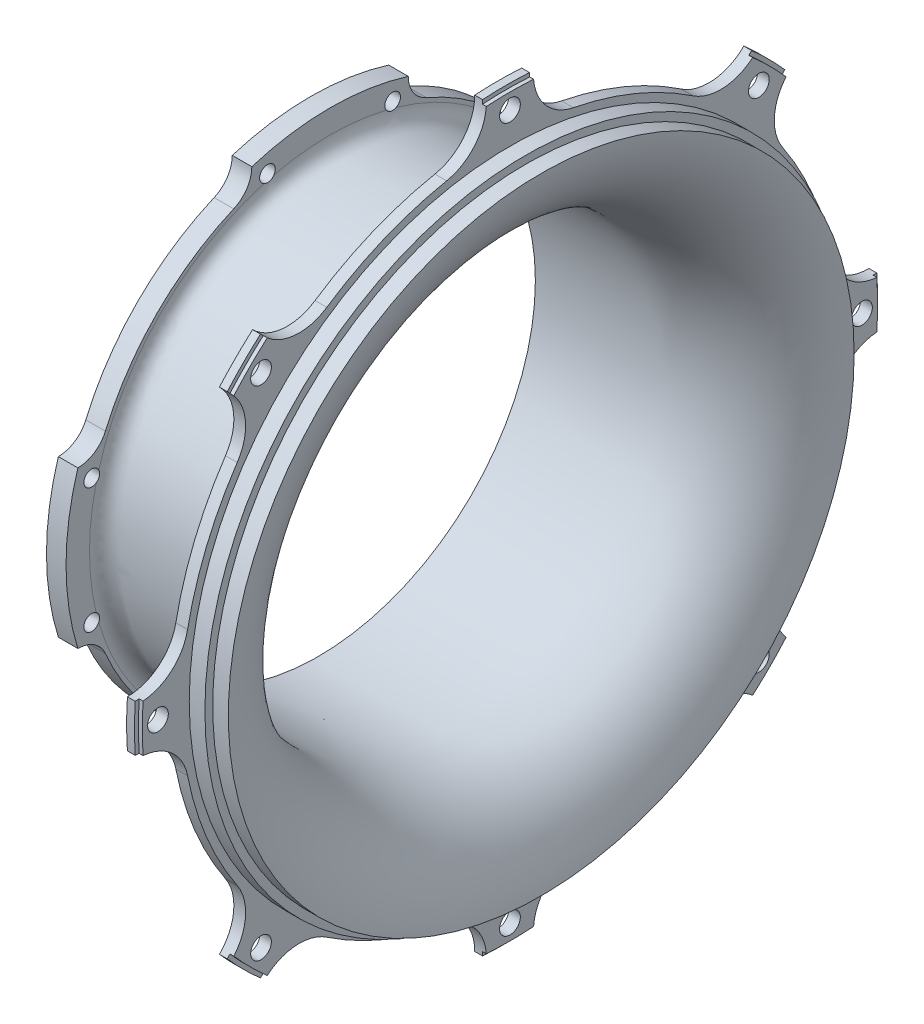
from build123d import *

# Parameters (mm, degrees)
BOSS_EXTRUDE1_DEPTH        = 3
M5_CLEARANCE_HOLE1_D       = 5.3
CIRPATTERN2_COUNT          = 8
SKETCH3_W                  = 1
SKETCH3_H                  = 1
BOSS_EXTRUDE2_DEPTH        = 5
M4_TAPPED_HOLE1_AT_2_COUNT = 2
M4_TAPPED_HOLE1_AT_2_PITCH = 32
CIRPATTERN3_COUNT          = 4


with BuildPart() as part:
    # Sketch1 → Revolve1 (revolve)
    with BuildSketch(Plane.XY, mode=Mode.PRIVATE) as revolve1_sk:
        with BuildLine():
            Line((26.884010118, 80), (22.884010118, 80))
            Line((22.884010118, 80), (22.884010118, 82))
            Line((22.884010118, 82), (18.884010118, 82))
            Line((18.884010118, 82), (18.884010118, 84))
            Line((18.884010118, 84), (15.884010118, 84))
            Line((15.884010118, 84), (15.884010118, 81))
            Line((15.884010118, 81), (22.904717658, 78.395093172))
            ThreePointArc((22.904717658, 78.395093172), (23.986444927, 77.436887697), (24.140215409, 76))
            add(Edge.make_bspline(
                [(24.140215409, 76), (21.925204116, 67.773715422), (16.096743453, 61.560255894), (8.028749254, 58.824291237), (7.172505876, 58.533927665), (5.428515706, 58.046099878), (2.71241102, 57.5), (0.904137007, 57.5), (0, 57.5), (-0.64211083, 57.5), (-1.92633249, 57.5), (-3.85266498, 57.5), (-5.136886641, 57.5), (-5.778997471, 57.5), (-11.037754083, 57.5), (-16.296510694, 57.5), (-21.555267306, 57.5), (-21.728680926, 57.5), (-22.075508165, 57.5), (-22.595749024, 57.5), (-22.942576263, 57.5), (-23.115989882, 57.5), (-23.289403502, 57.5), (-23.636230741, 57.5), (-24.157452607, 57.626231688), (-24.486510318, 57.738119351), (-24.646723612, 57.80448187), (-26.1887189, 58.443197231), (-27.115989882, 59.830956327), (-27.115989882, 61.5)],
                knots=[0, 0, 0, 0, 0.387277446, 0.387277446, 0.387277446, 0.431883511, 0.476489576, 0.521095641, 0.521095641, 0.521095641, 0.55277451, 0.584453379, 0.616132247, 0.616132247, 0.616132247, 0.875575715, 0.875575715, 0.875575715, 0.884131165, 0.892686615, 0.901242066, 0.901242066, 0.901242066, 0.909797516, 0.918352966, 0.926908417, 0.926908417, 0.926908417, 1, 1, 1, 1], degree=3, weights=[1, 0.921424889, 0.921424889, 1, 1, 1, 1, 1, 1, 1, 1, 1, 1, 1, 1, 1, 1, 1, 1, 1, 1, 1, 1, 1, 1, 1, 1, 0.887646408, 0.887646408, 1]))
            Line((-27.115989882, 61.5), (-27.115989882, 62.5))
            Line((-27.115989882, 62.5), (-32.115989882, 62.5))
            Line((-32.115989882, 62.5), (-32.115989882, 58.5))
            Line((-32.115989882, 58.5), (-30.115989882, 58.5))
            Line((-30.115989882, 58.5), (-30.115989882, 55.5))
            add(Edge.make_bspline(
                [(26.884010118, 80), (25.909531142, 69.520838946), (19.565470353, 61.123498988), (9.751475397, 57.322455887), (8.723618902, 56.924358389), (6.619149717, 56.254048066), (3.306771132, 55.5), (1.102257044, 55.5), (0, 55.5), (-0.836555275, 55.5), (-2.509665824, 55.5), (-5.019331647, 55.5), (-6.692442196, 55.5), (-7.528997471, 55.5), (-15.057994941, 55.5), (-22.586992412, 55.5), (-30.115989882, 55.5)],
                knots=[0, 0, 0, 0, 0.415170124, 0.415170124, 0.415170124, 0.463473748, 0.511777373, 0.560080997, 0.560080997, 0.560080997, 0.596740914, 0.633400831, 0.670060748, 0.670060748, 0.670060748, 1, 1, 1, 1], degree=3, weights=[1, 0.900187608, 0.900187608, 1, 1, 1, 1, 1, 1, 1, 1, 1, 1, 1, 1, 1, 1]))
        make_face()
    revolve(revolve1_sk.sketch.rotate(Axis((21.060706508, 0, 0), (-1, 0, 0)), 90), axis=Axis((21.060706508, 0, 0), (-1, 0, 0)))

    # Sketch2 → Boss-Extrude1 (add)
    with BuildSketch(Plane.ZY.offset(-15.884010118)):
        with BuildLine():
            ThreePointArc((6, 94.810336989), (0, 95), (-6, 94.810336989))
            ThreePointArc((-6, 94.810336989), (-8.874660383, 86.791417172), (-16.189212499, 82.425174544))
            ThreePointArc((-16.189212499, 82.425174544), (0, 84), (16.189212499, 82.425174544))
            ThreePointArc((16.189212499, 82.425174544), (8.874660383, 86.791417172), (6, 94.810336989))
        make_face()
    boss_extrude1 = extrude(amount=-BOSS_EXTRUDE1_DEPTH)

    # M5 Clearance Hole1 (through all)
    with Locations(Plane.ZY.offset(-15.884010118)):
        with Locations((0, 90)):
            m5_clearance_hole1 = Hole(M5_CLEARANCE_HOLE1_D / 2)

    # CirPattern2: Boss-Extrude1, M5 Clearance Hole1 ×8 about axis
    cirpattern2_axis = Axis((0, 0, 0), (1, 0, 0))
    add([boss_extrude1.rotate(cirpattern2_axis, i * 360 / CIRPATTERN2_COUNT) for i in range(1, CIRPATTERN2_COUNT)])
    add([m5_clearance_hole1.rotate(cirpattern2_axis, i * 360 / CIRPATTERN2_COUNT) for i in range(1, CIRPATTERN2_COUNT)], mode=Mode.SUBTRACT)

    # Sketch3 → Cut-Revolve1 (revolve, cut)
    with BuildSketch(Plane.XY):
        with Locations((18.384010118, 94.5)):
            Rectangle(SKETCH3_W, SKETCH3_H)
    revolve(axis=Axis((-27.669802315, 0, 0), (1, 0, 0)), mode=Mode.SUBTRACT)

    # Sketch8 → Boss-Extrude2 (add)
    with BuildSketch(Plane.ZY.offset(32.115989882)):
        with BuildLine():
            ThreePointArc((20, 64.468984791), (0, 67.5), (-20, 64.468984791))
            ThreePointArc((-20, 64.468984791), (-21.262497448, 60.260079388), (-24.63312369, 57.440919363))
            ThreePointArc((-24.63312369, 57.440919363), (0, 62.5), (24.63312369, 57.440919363))
            ThreePointArc((24.63312369, 57.440919363), (21.262497448, 60.260079388), (20, 64.468984791))
        make_face()
    boss_extrude2 = extrude(amount=-BOSS_EXTRUDE2_DEPTH)

    # Sketch9 → M4 Tapped Hole1 (revolve, cut)
    with BuildSketch(Plane(origin=(-32.115989882, 60.934390946, -16), x_dir=(0, 0, 1), z_dir=(0, 1, 0))):
        Polygon((0, 0), (0, 11.241420021), (1.65, 10.25), (1.65, 8), (2, 8), (2, 0), align=None)
    m4_tapped_hole1 = revolve(axis=Axis((-38.465989882, 60.934390946, -16), (1, 0, 0)), mode=Mode.SUBTRACT)

    # M4 Tapped Hole1 at 2: M4 Tapped Hole1 ×2
    with Locations(*[(0, 0, i * M4_TAPPED_HOLE1_AT_2_PITCH) for i in range(1, M4_TAPPED_HOLE1_AT_2_COUNT)]):
        add(m4_tapped_hole1, mode=Mode.SUBTRACT)

    # CirPattern3: Boss-Extrude2, M4 Tapped Hole1 ×4 about axis
    cirpattern3_axis = Axis((0, 0, 0), (1, 0, 0))
    add([boss_extrude2.rotate(cirpattern3_axis, i * 360 / CIRPATTERN3_COUNT) for i in range(1, CIRPATTERN3_COUNT)])
    add([m4_tapped_hole1.rotate(cirpattern3_axis, i * 360 / CIRPATTERN3_COUNT) for i in range(1, CIRPATTERN3_COUNT)], mode=Mode.SUBTRACT)

    # CirPattern3 copy 1 sketch → CirPattern3 copy 1 (revolve, cut)
    with BuildSketch(Plane(origin=(-32.115989882, -16, 60.934390946), x_dir=(0, -1, 0), z_dir=(0, 0, 1))):
        Polygon((0, 0), (0, 11.241420021), (1.65, 10.25), (1.65, 8), (2, 8), (2, 0), align=None)
    revolve(axis=Axis((-38.465989882, -16, 60.934390946), (1, 0, 0)), mode=Mode.SUBTRACT)

    # CirPattern3 copy 2 sketch → CirPattern3 copy 2 (revolve, cut)
    with BuildSketch(Plane(origin=(-32.115989882, -60.934390946, -16), x_dir=(0, 0, -1), z_dir=(0, -1, 0))):
        Polygon((0, 0), (0, 11.241420021), (1.65, 10.25), (1.65, 8), (2, 8), (2, 0), align=None)
    revolve(axis=Axis((-38.465989882, -60.934390946, -16), (1, 0, 0)), mode=Mode.SUBTRACT)

    # CirPattern3 copy 3 sketch → CirPattern3 copy 3 (revolve, cut)
    with BuildSketch(Plane(origin=(-32.115989882, 16, -60.934390946), x_dir=(0, 1, 0), z_dir=(0, 0, -1))):
        Polygon((0, 0), (0, 11.241420021), (1.65, 10.25), (1.65, 8), (2, 8), (2, 0), align=None)
    revolve(axis=Axis((-38.465989882, 16, -60.934390946), (1, 0, 0)), mode=Mode.SUBTRACT)


solid = part.part
